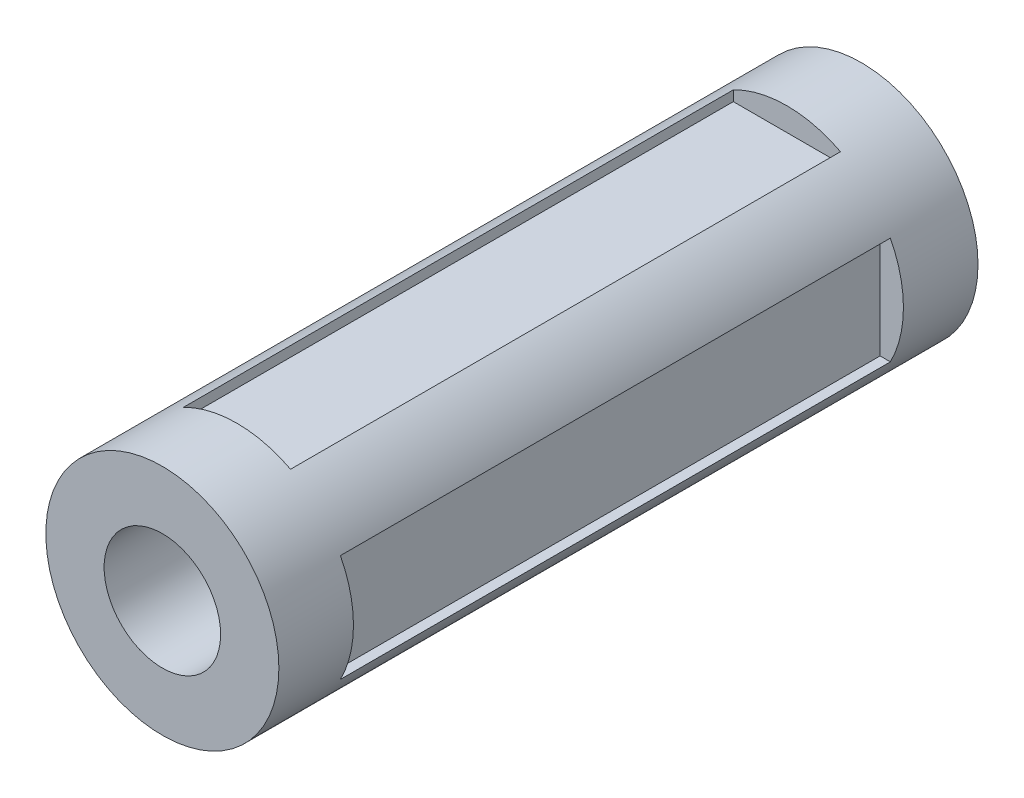
from build123d import *

# Parameters (mm, degrees)
SKETCH1_R           = 50
SKETCH1_R_2         = 25
BOSS_EXTRUDE1_DEPTH = 300
CUT_EXTRUDE1_DEPTH  = 10
CIRPATTERN1_COUNT   = 4


with BuildPart() as part:
    # Sketch1 → Boss-Extrude1 (new body)
    with BuildSketch(Plane.XY):
        Circle(SKETCH1_R)
        Circle(SKETCH1_R_2, mode=Mode.SUBTRACT)
    extrude(amount=BOSS_EXTRUDE1_DEPTH)

    # Sketch2 → Cut-Extrude1 (cut)
    with BuildSketch(Plane(origin=(0, 50, 0), x_dir=(1, 0, 0), z_dir=(0, 1, 0))):
        Polygon((-22.999966335, -268), (-22.995993926, -32), (22.995993926, -32), (22.999966335, -268), align=None)
    cut_extrude1 = extrude(amount=-CUT_EXTRUDE1_DEPTH, mode=Mode.SUBTRACT)

    # CirPattern1: Cut-Extrude1 ×4 about axis
    cirpattern1_axis = Axis((0, 0, 0), (0, 0, 1))
    for i in range(1, CIRPATTERN1_COUNT):
        add(cut_extrude1.rotate(cirpattern1_axis, i * 360 / CIRPATTERN1_COUNT), mode=Mode.SUBTRACT)


solid = part.part
